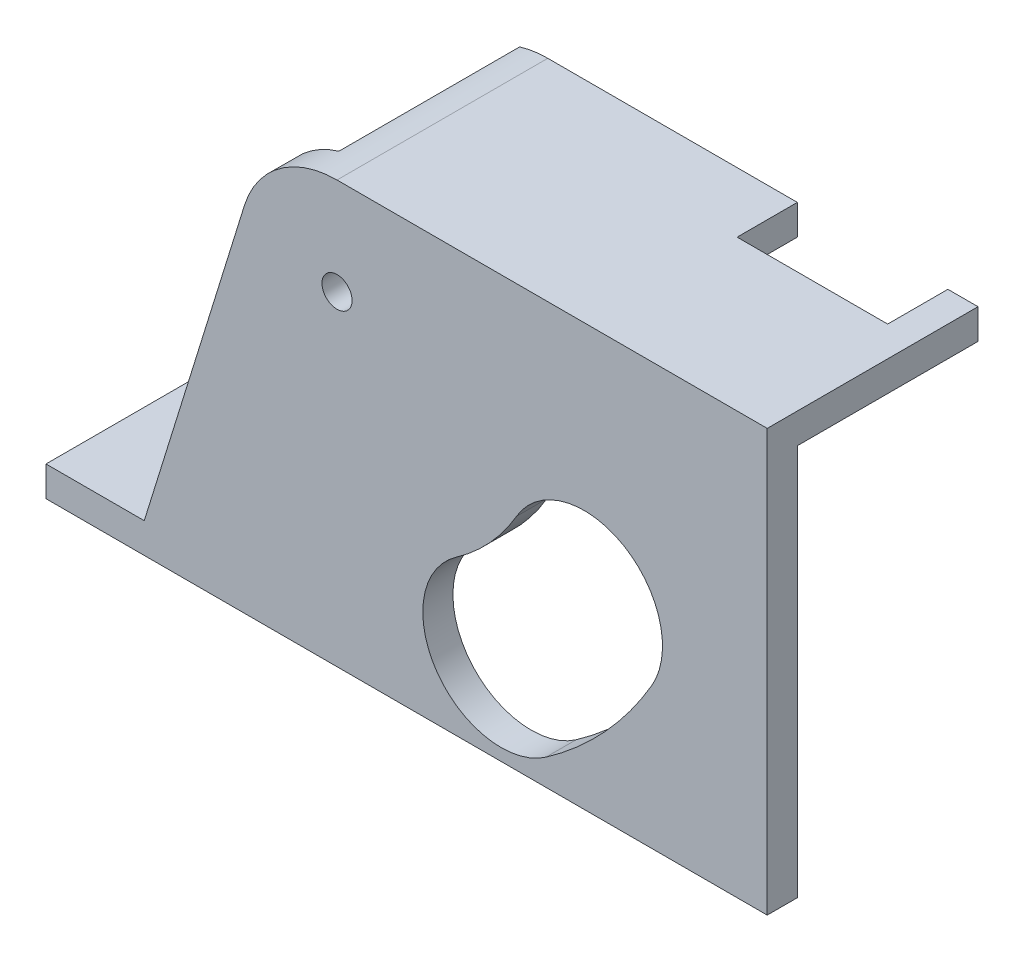
from build123d import *

# Parameters (mm, degrees)
SKETCH1_W           = 120
SKETCH1_H           = 100
BOSS_EXTRUDE1_DEPTH = 5
SKETCH2_R           = 2.5
CUT_EXTRUDE1_DEPTH  = 6
CUT_EXTRUDE3_DEPTH  = 10
BOSS_EXTRUDE3_DEPTH = 30
SKETCH8_W           = 20
SKETCH8_H           = 5
BOSS_EXTRUDE4_DEPTH = 35
SKETCH9_W           = 25
SKETCH9_H           = 10
CUT_EXTRUDE4_DEPTH  = 71


with BuildPart() as part:
    # Sketch1 → Boss-Extrude1 (new body)
    with BuildSketch(Plane.XY):
        with Locations((60, 50)):
            Rectangle(SKETCH1_W, SKETCH1_H)
    extrude(amount=BOSS_EXTRUDE1_DEPTH)

    # Sketch2 → Cut-Extrude1 (cut, through all)
    with BuildSketch(Plane.XY.offset(5)):
        with Locations((48.561388608, 53.909722104)):
            Circle(SKETCH2_R)
        with BuildLine():
            ThreePointArc((83.262763007, 4.351023424), (93.087143476, 12.949898455), (100.837944203, 23.456286582))
            ThreePointArc((100.837944203, 23.456286582), (96.148678733, 41.232978888), (78.371986427, 36.543713418))
            ThreePointArc((78.371986427, 36.543713418), (73.952108326, 30.552467296), (68.349775662, 25.648976576))
            ThreePointArc((68.349775662, 25.648976576), (65.157292759, 7.543506327), (83.262763007, 4.351023424))
        make_face()
    extrude(amount=-CUT_EXTRUDE1_DEPTH, mode=Mode.SUBTRACT)

    # Sketch5 → Cut-Extrude3 (cut)
    with BuildSketch(Plane.XY.offset(5)):
        with BuildLine():
            Line((120, 70), (48.561388608, 70))
            ThreePointArc((48.561388608, 70), (39.016134462, 66.862913451), (33.192915272, 58.674915711))
            Line((33.192915272, 58.674915711), (15, 0))
            Line((15, 0), (0, 0))
            Line((0, 0), (0, 100))
            Line((0, 100), (120, 100))
            Line((120, 100), (120, 70))
        make_face()
    extrude(amount=-CUT_EXTRUDE3_DEPTH, mode=Mode.SUBTRACT)

    # Sketch7 → Boss-Extrude3 (add)
    with BuildSketch(Plane(origin=(0, 0, 0), x_dir=(-1, 0, 0), z_dir=(0, 0, -1))):
        Polygon((-15, 0), (-32.773002065, 57.320631823), (-37.206950606, 54.737658166), (-20.234832877, 0), align=None)
        with BuildLine():
            Line((-120, 70), (-48.561388608, 70))
            ThreePointArc((-48.561388608, 70), (-46.197570118, 69.825418913), (-43.885046952, 69.305464096))
            Line((-43.885046952, 69.305464096), (-47.035737431, 64.805811769))
            ThreePointArc((-47.035737431, 64.805811769), (-47.792408669, 64.951257894), (-48.561388608, 65))
            Line((-48.561388608, 65), (-120, 65))
            Line((-120, 65), (-120, 70))
        make_face()
    extrude(amount=BOSS_EXTRUDE3_DEPTH)

    # Sketch8 → Boss-Extrude4 (add, through all)
    with BuildSketch(Plane(origin=(0, 0, -30), x_dir=(-1, 0, 0), z_dir=(0, 0, -1))):
        with Locations((-10.234832877, 2.5)):
            Rectangle(SKETCH8_W, SKETCH8_H)
    extrude(amount=-BOSS_EXTRUDE4_DEPTH)

    # Sketch9 → Cut-Extrude4 (cut, through all)
    with BuildSketch(Plane(origin=(0, 70, 0), x_dir=(1, 0, 0), z_dir=(0, 1, 0))):
        with Locations((102.5, 25)):
            Rectangle(SKETCH9_W, SKETCH9_H)
    extrude(amount=-CUT_EXTRUDE4_DEPTH, mode=Mode.SUBTRACT)


solid = part.part
